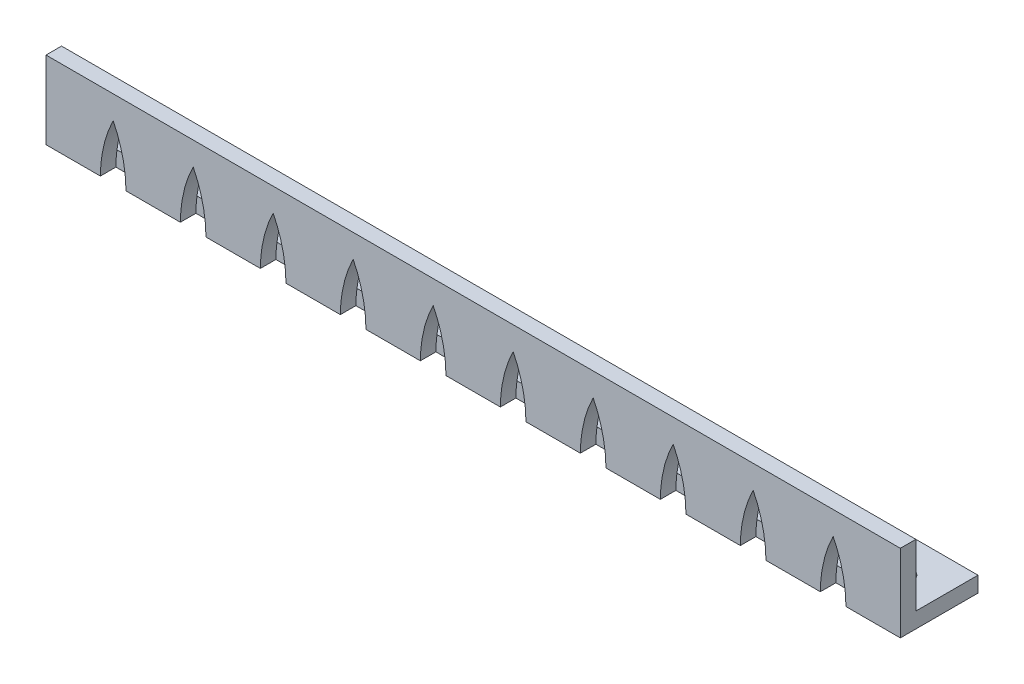
from build123d import *

# Parameters (mm, degrees)
SKETCH1_W                      = 110
SKETCH1_H                      = 10
SKETCH1_R                      = 1.5025
BOSS_EXTRUDE1_DEPTH            = 10
CUT_EXTRUDE1_REACH             = 7
SKETCH2_W                      = 110
SKETCH2_H                      = 8
CUT_EXTRUDE1_DIRECTION_2_DEPTH = 3
CUT_EXTRUDE2_DEPTH             = 2


with BuildPart() as part:
    # Sketch1 → Boss-Extrude1 (new body)
    with BuildSketch(Plane(origin=(0, 0, 0), x_dir=(1, 0, 0), z_dir=(0, 1, 0))):
        Rectangle(SKETCH1_W, SKETCH1_H)
        with Locations((-50, 0)):
            Circle(SKETCH1_R, mode=Mode.SUBTRACT)
        with Locations((-40, 0)):
            Circle(SKETCH1_R, mode=Mode.SUBTRACT)
        with Locations((-30, 0)):
            Circle(SKETCH1_R, mode=Mode.SUBTRACT)
        with Locations((-20, 0)):
            Circle(SKETCH1_R, mode=Mode.SUBTRACT)
        with Locations((-10, 0)):
            Circle(SKETCH1_R, mode=Mode.SUBTRACT)
        Circle(SKETCH1_R, mode=Mode.SUBTRACT)
        with Locations((10, 0)):
            Circle(SKETCH1_R, mode=Mode.SUBTRACT)
        with Locations((20, 0)):
            Circle(SKETCH1_R, mode=Mode.SUBTRACT)
        with Locations((30, 0)):
            Circle(SKETCH1_R, mode=Mode.SUBTRACT)
        with Locations((40, 0)):
            Circle(SKETCH1_R, mode=Mode.SUBTRACT)
        with Locations((50, 0)):
            Circle(SKETCH1_R, mode=Mode.SUBTRACT)
    extrude(amount=BOSS_EXTRUDE1_DEPTH)

    # Sketch2 → Cut-Extrude1 (cut, up to next)
    with BuildSketch(Plane.XY, mode=Mode.PRIVATE) as cut_extrude1_sk1:
        with Locations((0, 6)):
            Rectangle(SKETCH2_W, SKETCH2_H)
    cut_extrude1_tool1 = extrude(cut_extrude1_sk1.sketch, amount=-CUT_EXTRUDE1_REACH, mode=Mode.PRIVATE) & part.part
    add(cut_extrude1_tool1.solids().sort_by_distance((0, 6, 0))[0], mode=Mode.SUBTRACT)

    # Sketch2 → Cut-Extrude1 direction 2 (cut)
    with BuildSketch(Plane.XY):
        with Locations((0, 6)):
            Rectangle(SKETCH2_W, SKETCH2_H)
    extrude(amount=CUT_EXTRUDE1_DIRECTION_2_DEPTH, mode=Mode.SUBTRACT)

    # Sketch3 → Cut-Extrude2 (cut)
    with BuildSketch(Plane.XY.offset(5)):
        with BuildLine():
            Line((-37.7, 0), (-34.4, 0))
            add(Edge.make_bspline(
                [(-36.05, 7), (-34.434888234, 3.724961413), (-34.4, 0)],
                knots=[0, 0, 0, 1, 1, 1], degree=2))
            add(Edge.make_bspline(
                [(-36.05, 7), (-37.665111766, 3.724961413), (-37.7, 0)],
                knots=[0, 0, 0, 1, 1, 1], degree=2))
        make_face()
        with BuildLine():
            Line((-48, 0), (-44.7, 0))
            add(Edge.make_bspline(
                [(-46.35, 7), (-44.734888234, 3.724961413), (-44.7, 0)],
                knots=[0, 0, 0, 1, 1, 1], degree=2))
            add(Edge.make_bspline(
                [(-46.35, 7), (-47.965111766, 3.724961413), (-48, 0)],
                knots=[0, 0, 0, 1, 1, 1], degree=2))
        make_face()
        with BuildLine():
            Line((-27.4, 0), (-24.1, 0))
            add(Edge.make_bspline(
                [(-25.75, 7), (-24.134888234, 3.724961413), (-24.1, 0)],
                knots=[0, 0, 0, 1, 1, 1], degree=2))
            add(Edge.make_bspline(
                [(-25.75, 7), (-27.365111766, 3.724961413), (-27.4, 0)],
                knots=[0, 0, 0, 1, 1, 1], degree=2))
        make_face()
        with BuildLine():
            Line((-17.1, 0), (-13.8, 0))
            add(Edge.make_bspline(
                [(-15.45, 7), (-13.834888234, 3.724961413), (-13.8, 0)],
                knots=[0, 0, 0, 1, 1, 1], degree=2))
            add(Edge.make_bspline(
                [(-15.45, 7), (-17.065111766, 3.724961413), (-17.1, 0)],
                knots=[0, 0, 0, 1, 1, 1], degree=2))
        make_face()
        with BuildLine():
            Line((-6.8, 0), (-3.5, 0))
            add(Edge.make_bspline(
                [(-5.15, 7), (-3.534888234, 3.724961413), (-3.5, 0)],
                knots=[0, 0, 0, 1, 1, 1], degree=2))
            add(Edge.make_bspline(
                [(-5.15, 7), (-6.765111766, 3.724961413), (-6.8, 0)],
                knots=[0, 0, 0, 1, 1, 1], degree=2))
        make_face()
        with BuildLine():
            Line((3.5, 0), (6.8, 0))
            add(Edge.make_bspline(
                [(5.15, 7), (6.765111766, 3.724961413), (6.8, 0)],
                knots=[0, 0, 0, 1, 1, 1], degree=2))
            add(Edge.make_bspline(
                [(5.15, 7), (3.534888234, 3.724961413), (3.5, 0)],
                knots=[0, 0, 0, 1, 1, 1], degree=2))
        make_face()
        with BuildLine():
            Line((13.8, 0), (17.1, 0))
            add(Edge.make_bspline(
                [(15.45, 7), (17.065111766, 3.724961413), (17.1, 0)],
                knots=[0, 0, 0, 1, 1, 1], degree=2))
            add(Edge.make_bspline(
                [(15.45, 7), (13.834888234, 3.724961413), (13.8, 0)],
                knots=[0, 0, 0, 1, 1, 1], degree=2))
        make_face()
        with BuildLine():
            Line((24.1, 0), (27.4, 0))
            add(Edge.make_bspline(
                [(25.75, 7), (27.365111766, 3.724961413), (27.4, 0)],
                knots=[0, 0, 0, 1, 1, 1], degree=2))
            add(Edge.make_bspline(
                [(25.75, 7), (24.134888234, 3.724961413), (24.1, 0)],
                knots=[0, 0, 0, 1, 1, 1], degree=2))
        make_face()
        with BuildLine():
            Line((34.4, 0), (37.7, 0))
            add(Edge.make_bspline(
                [(36.05, 7), (37.665111766, 3.724961413), (37.7, 0)],
                knots=[0, 0, 0, 1, 1, 1], degree=2))
            add(Edge.make_bspline(
                [(36.05, 7), (34.434888234, 3.724961413), (34.4, 0)],
                knots=[0, 0, 0, 1, 1, 1], degree=2))
        make_face()
        with BuildLine():
            Line((44.7, 0), (48, 0))
            add(Edge.make_bspline(
                [(46.35, 7), (47.965111766, 3.724961413), (48, 0)],
                knots=[0, 0, 0, 1, 1, 1], degree=2))
            add(Edge.make_bspline(
                [(46.35, 7), (44.734888234, 3.724961413), (44.7, 0)],
                knots=[0, 0, 0, 1, 1, 1], degree=2))
        make_face()
    extrude(amount=-CUT_EXTRUDE2_DEPTH, mode=Mode.SUBTRACT)


solid = part.part
